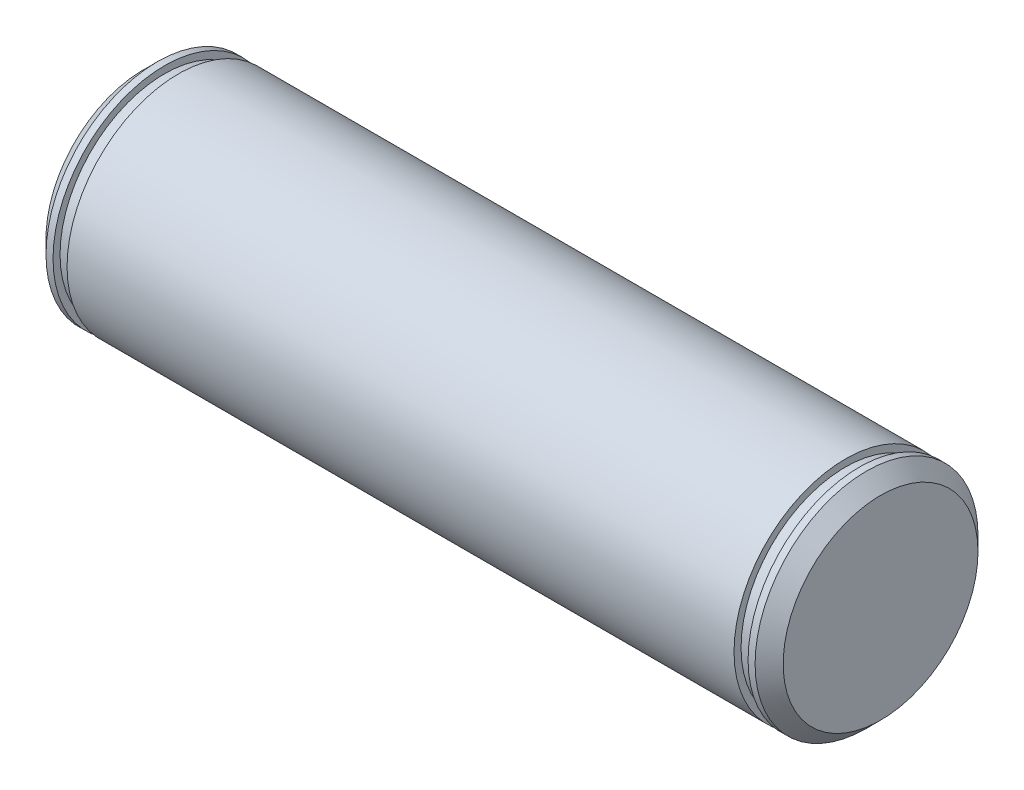
from build123d import *

# Parameters (mm, degrees)
SKETCH1_R           = 15.875
BOSS_EXTRUDE1_DEPTH = 52.5
CHAMFER1_SIZE       = 2
SKETCH2_R           = 15.875
SKETCH2_R_2         = 14.875
CUT_EXTRUDE1_DEPTH  = 2


with BuildPart() as part:
    # Sketch1 → Boss-Extrude1 (new body, symmetric)
    with BuildSketch(Plane(origin=(0, 0, 0), x_dir=(0, 0, -1), z_dir=(1, 0, 0))):
        Circle(SKETCH1_R)
    extrude(amount=BOSS_EXTRUDE1_DEPTH, both=True)

    # Chamfer1
    chamfer1_edges = [part.edges().sort_by_distance(p)[0] for p in [
        (-52.5, 0, 15.875),
        (52.5, 0, 15.875),
    ]]
    chamfer(chamfer1_edges, length=CHAMFER1_SIZE)

    # Sketch2 → Cut-Extrude1 (cut)
    with BuildSketch(Plane.ZY.offset(47.5)):
        Circle(SKETCH2_R)
        Circle(SKETCH2_R_2, mode=Mode.SUBTRACT)
    cut_extrude1 = extrude(amount=CUT_EXTRUDE1_DEPTH, mode=Mode.SUBTRACT)

    # Mirror1: Cut-Extrude1 across plane
    add(cut_extrude1.mirror(Plane(origin=(0, 0, 0), x_dir=(0, 0, 1), z_dir=(1, 0, 0))), mode=Mode.SUBTRACT)


solid = part.part
